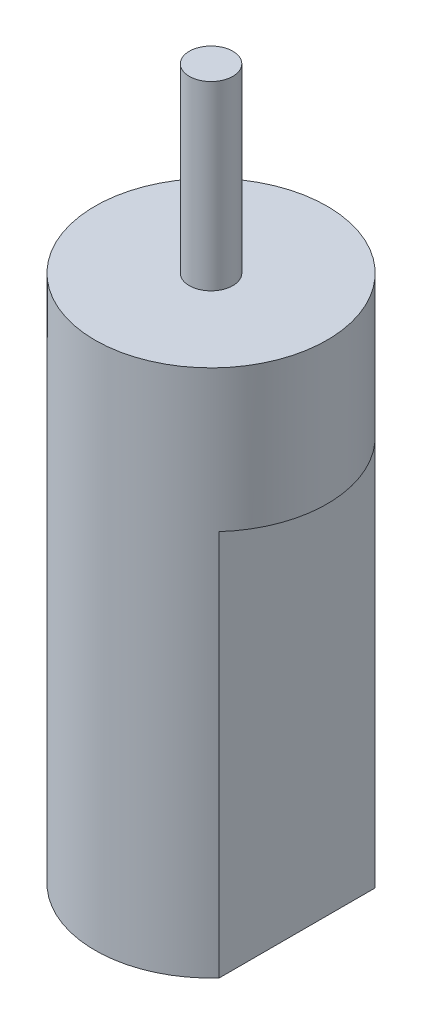
from build123d import *

# Parameters (mm, degrees)
SKETCH1_R           = 8
BOSS_EXTRUDE1_DEPTH = 36.4236
CUT_EXTRUDE1_DEPTH  = 26.6446
SKETCH3_R           = 1.5
BOSS_EXTRUDE2_DEPTH = 12.4968


with BuildPart() as part:
    # Sketch1 → Boss-Extrude1 (new body)
    with BuildSketch(Plane(origin=(0, 0, 0), x_dir=(1, 0, 0), z_dir=(0, 1, 0))):
        Circle(SKETCH1_R)
    extrude(amount=BOSS_EXTRUDE1_DEPTH)

    # Sketch2 → Cut-Extrude1 (cut)
    with BuildSketch(Plane.XZ):
        with BuildLine():
            Line((5.9309, 5.368838346), (5.9309, -5.368838346))
            ThreePointArc((5.9309, -5.368838346), (8, 0), (5.9309, 5.368838346))
        make_face()
        with BuildLine():
            Line((-5.9309, 5.368838346), (-5.9309, -5.368838346))
            ThreePointArc((-5.9309, -5.368838346), (-8, 0), (-5.9309, 5.368838346))
        make_face()
    extrude(amount=-CUT_EXTRUDE1_DEPTH, mode=Mode.SUBTRACT)

    # Sketch3 → Boss-Extrude2 (add)
    with BuildSketch(Plane(origin=(0, 36.4236, 0), x_dir=(1, 0, 0), z_dir=(0, 1, 0))):
        Circle(SKETCH3_R)
    extrude(amount=BOSS_EXTRUDE2_DEPTH)


solid = part.part
